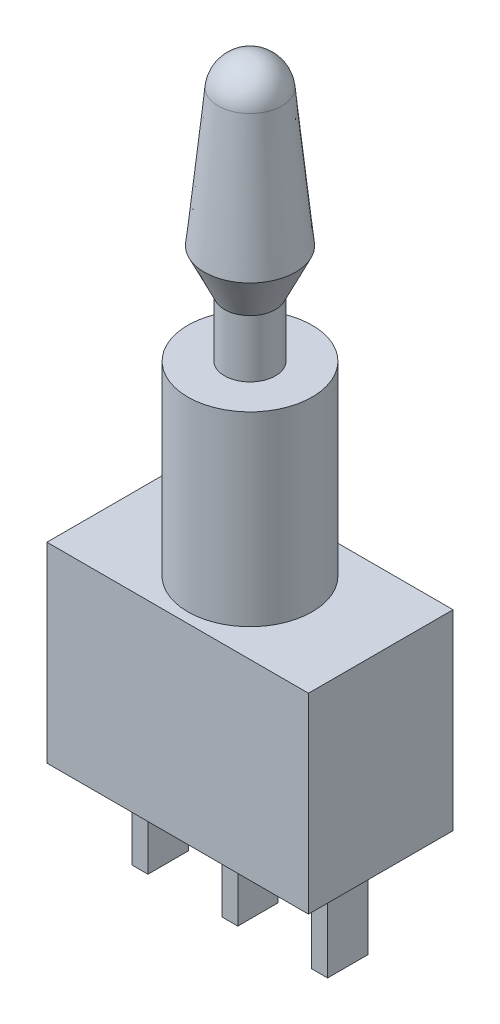
from build123d import *

# Parameters (mm, degrees)
SKETCH1_W           = 12.3
SKETCH1_H           = 6.8
BOSS_EXTRUDE1_DEPTH = 9
SKETCH2_R           = 2.925
BOSS_EXTRUDE2_DEPTH = 8.75
SKETCH4_W           = 0.75
SKETCH4_H           = 1.9
BOSS_EXTRUDE3_DEPTH = 4.6


with BuildPart() as part:
    # Sketch1 → Boss-Extrude1 (new body)
    with BuildSketch(Plane(origin=(0, 0, 0), x_dir=(1, 0, 0), z_dir=(0, 1, 0))):
        Rectangle(SKETCH1_W, SKETCH1_H)
    extrude(amount=BOSS_EXTRUDE1_DEPTH)

    # Sketch2 → Boss-Extrude2 (add)
    with BuildSketch(Plane(origin=(0, 9, 0), x_dir=(1, 0, 0), z_dir=(0, 1, 0))):
        Circle(SKETCH2_R)
    extrude(amount=BOSS_EXTRUDE2_DEPTH)

    # Sketch3 → Revolve1 (revolve)
    with BuildSketch(Plane.XY):
        with BuildLine():
            Line((0, 17.75), (1.2, 17.75))
            Line((1.2, 17.75), (1.2, 20.45))
            Line((1.2, 20.45), (2.15, 22.45))
            Line((2.15, 22.45), (1.5, 28.893698303))
            ThreePointArc((1.5, 28.893698303), (1.011132322, 29.860648085), (0, 30.25))
            Line((0, 30.25), (0, 17.75))
        make_face()
    revolve(axis=Axis((0, -982.25, 0), (0, 1, 0)))

    # Sketch4 → Boss-Extrude3 (add)
    with BuildSketch(Plane.XZ):
        Rectangle(SKETCH4_W, SKETCH4_H)
        with Locations((-4.225, 0)):
            Rectangle(SKETCH4_W, SKETCH4_H)
        with Locations((4.225, 0)):
            Rectangle(SKETCH4_W, SKETCH4_H)
    extrude(amount=BOSS_EXTRUDE3_DEPTH)


solid = part.part
